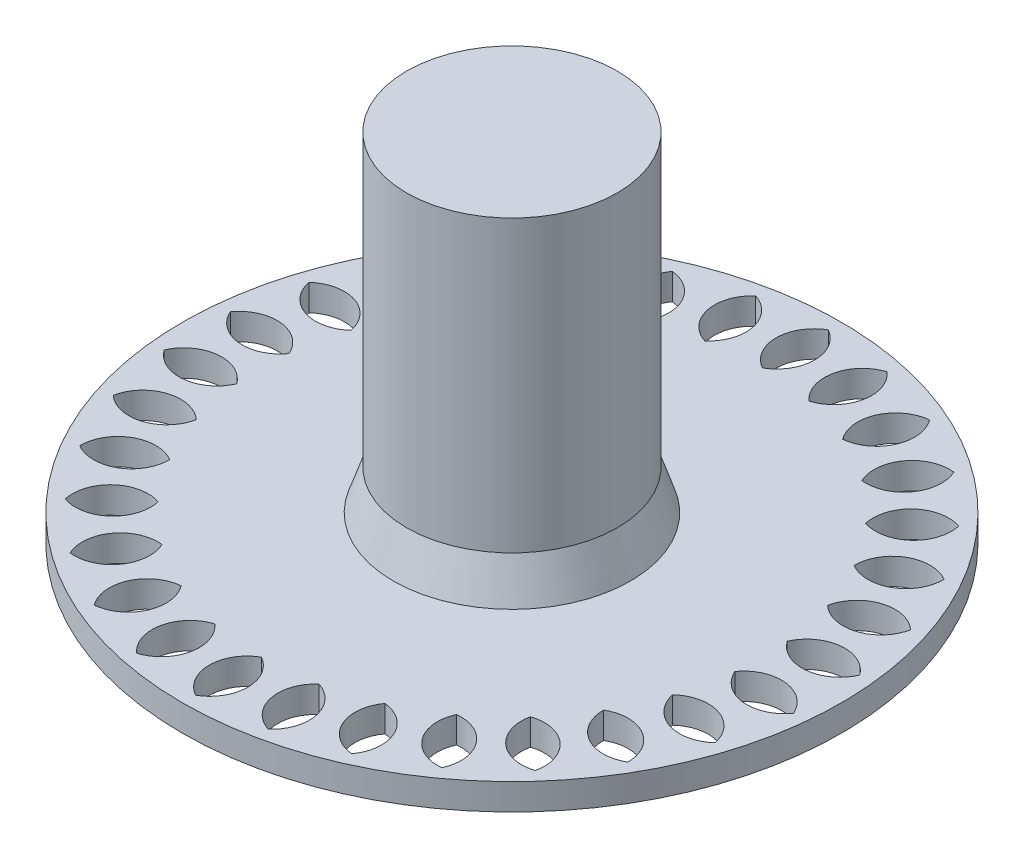
from build123d import *

# Parameters (mm, degrees)
SKETCH2_R           = 25
BOSS_EXTRUDE1_DEPTH = 2
CUT_EXTRUDE1_DEPTH  = 3
CIRPATTERN1_COUNT   = 30
SKETCH5_R           = 8
BOSS_EXTRUDE2_DEPTH = 22


with BuildPart() as part:
    # Sketch2 → Boss-Extrude1 (new body)
    with BuildSketch(Plane(origin=(0, 0, 0), x_dir=(1, 0, 0), z_dir=(0, 1, 0))):
        Circle(SKETCH2_R)
    extrude(amount=BOSS_EXTRUDE1_DEPTH)

    # Sketch1 → Cut-Extrude1 (cut, through all)
    with BuildSketch(Plane(origin=(0, 0, 0), x_dir=(1, 0, 0), z_dir=(0, 1, 0))):
        with BuildLine():
            ThreePointArc((0, 19), (-1.459542881, 21.5), (0, 24))
            ThreePointArc((0, 24), (1.459542881, 21.5), (0, 19))
        make_face()
    cut_extrude1 = extrude(amount=CUT_EXTRUDE1_DEPTH, mode=Mode.SUBTRACT)

    # CirPattern1: Cut-Extrude1 ×30 about axis
    cirpattern1_axis = Axis((0, 0, 0), (0, 1, 0))
    for i in range(1, CIRPATTERN1_COUNT):
        add(cut_extrude1.rotate(cirpattern1_axis, i * 360 / CIRPATTERN1_COUNT), mode=Mode.SUBTRACT)

    # Sketch4 → Revolve1 (revolve)
    with BuildSketch(Plane.XY):
        Polygon((-8, 5), (0, 5), (0, 2), (-9, 2), align=None)
    revolve(axis=Axis((0, 5, 0), (0, -1, 0)))

    # Sketch5 → Boss-Extrude2 (add)
    with BuildSketch(Plane(origin=(0, 5, 0), x_dir=(1, 0, 0), z_dir=(0, 1, 0))):
        Circle(SKETCH5_R)
    extrude(amount=BOSS_EXTRUDE2_DEPTH)


solid = part.part
